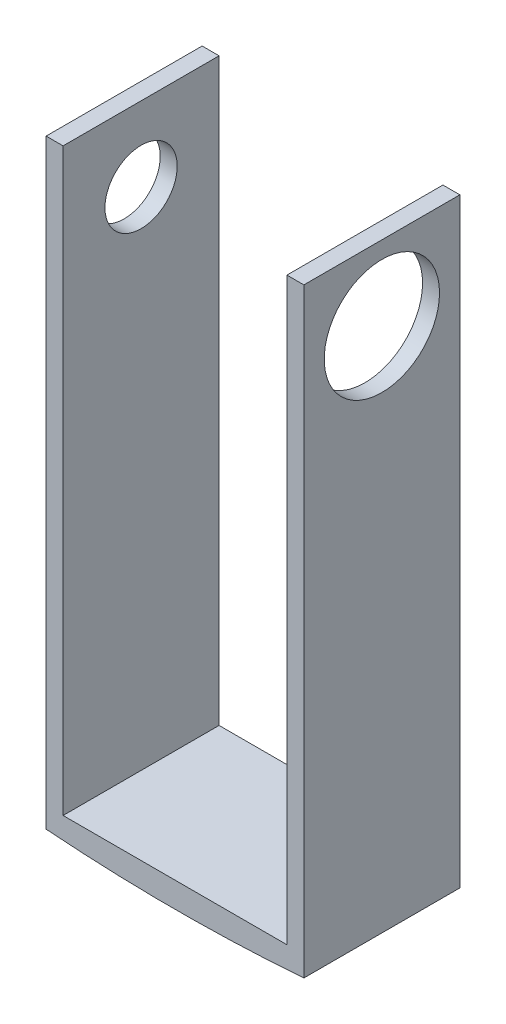
from build123d import *

# Parameters (mm, degrees)
BOSS_EXTRUDE1_DEPTH       = 5.842
F_6_32_TAPPED_HOLE1_D     = 2.7051
F_6_32_TAPPED_HOLE1_DEPTH = 0.635
CUT_EXTRUDE1_REACH        = 11.652
SKETCH6_R                 = 2.159
BOSS_EXTRUDE2_DEPTH       = 5.842


with BuildPart() as part:
    # Sketch1 → Boss-Extrude1 (new body)
    with BuildSketch(Plane.XY):
        Polygon((-3.353873239, 20.18718662), (-3.353873239, -2.29181338), (6.298126761, -2.29181338), (6.298126761, 20.18718662), (5.663126761, 20.18718662), (5.663126761, -1.52981338), (-2.718873239, -1.52981338), (-2.718873239, 20.18718662), align=None)
    extrude(amount=BOSS_EXTRUDE1_DEPTH)

    # #6-32 Tapped Hole1
    with Locations(Plane.ZY.offset(3.353873239)):
        with Locations((2.921, 17.39318662)):
            Hole(F_6_32_TAPPED_HOLE1_D / 2, depth=F_6_32_TAPPED_HOLE1_DEPTH)

    # Sketch6 → Cut-Extrude1 (cut, up to next)
    with BuildSketch(Plane(origin=(6.298126761, 0, 0), x_dir=(0, 0, -1), z_dir=(1, 0, 0)), mode=Mode.PRIVATE) as cut_extrude1_sk1:
        with Locations((-2.921, 17.39318662)):
            Circle(SKETCH6_R)
    cut_extrude1_tool1 = extrude(cut_extrude1_sk1.sketch, amount=-CUT_EXTRUDE1_REACH, mode=Mode.PRIVATE) & part.part
    add(cut_extrude1_tool1.solids().sort_by_distance((6.298127, 17.393187, 2.921))[0], mode=Mode.SUBTRACT)

    # Sketch15 → Boss-Extrude2 (add, through all)
    with BuildSketch(Plane.XY):
        with BuildLine():
            Line((6.298126761, -2.29181338), (-3.353873239, -2.29181338))
            ThreePointArc((-3.353873239, -2.29181338), (1.472126761, -2.477704159), (6.298126761, -2.29181338))
        make_face()
    extrude(amount=BOSS_EXTRUDE2_DEPTH)


solid = part.part
